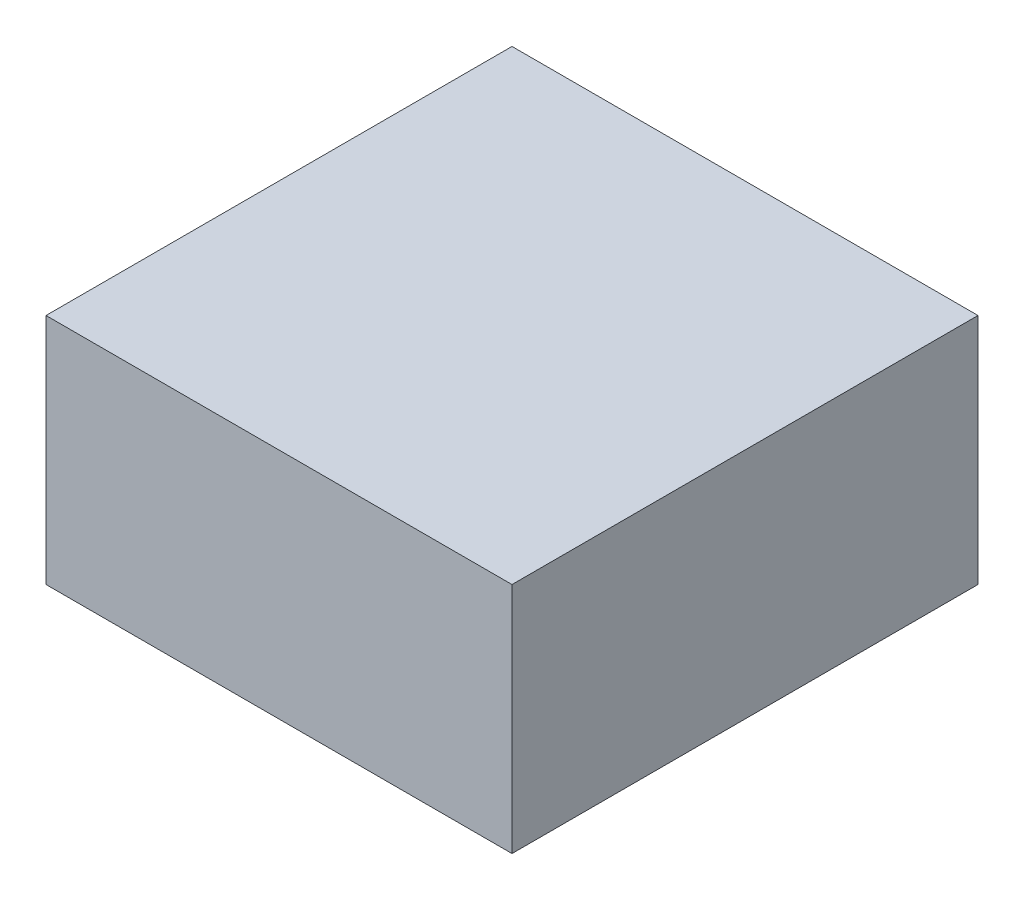
from build123d import *

# Parameters (mm, degrees)
SKETCH2_W           = 254
SKETCH2_H           = 254
BOSS_EXTRUDE1_DEPTH = 127


with BuildPart() as part:
    # Sketch2 → Boss-Extrude1 (new body)
    with BuildSketch(Plane(origin=(0, 0, 0), x_dir=(1, 0, 0), z_dir=(0, 1, 0))):
        with Locations((-55.562007996, -3.735294118)):
            Rectangle(SKETCH2_W, SKETCH2_H)
    extrude(amount=BOSS_EXTRUDE1_DEPTH)


solid = part.part
